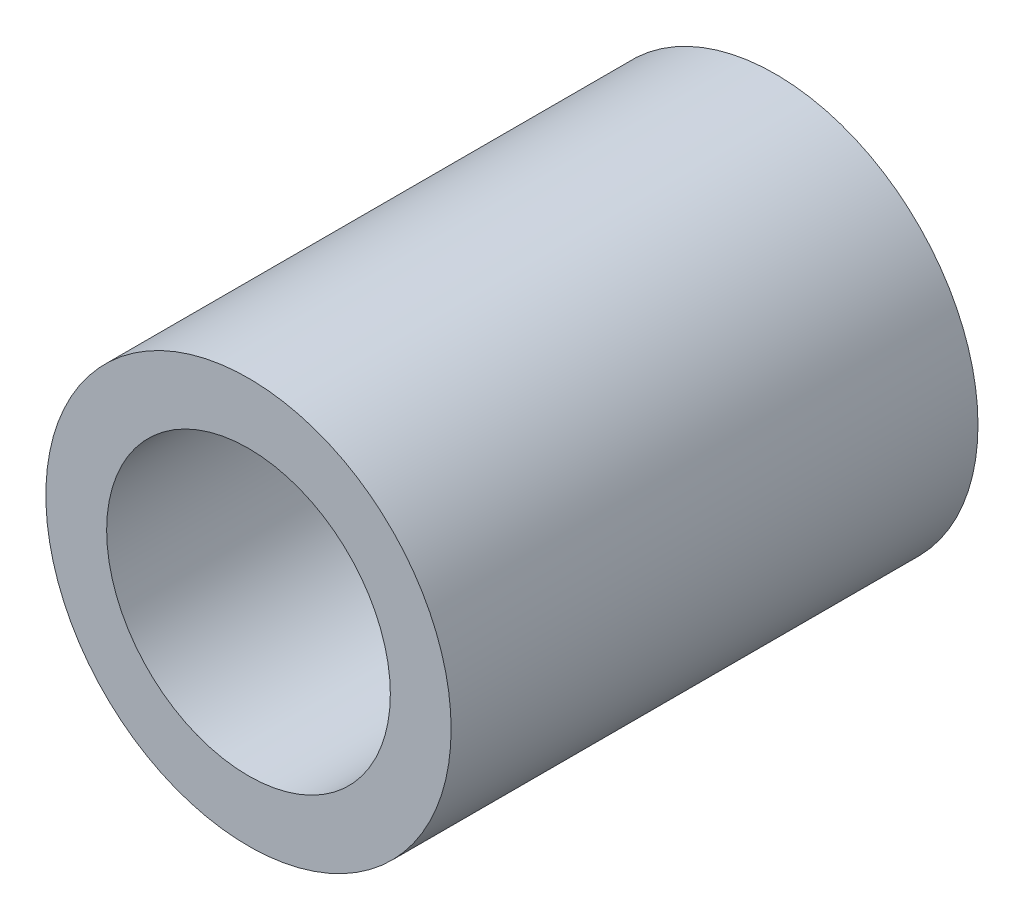
from build123d import *

# Parameters (mm, degrees)
ESBO_O1_R                = 2.5
ESBO_O1_R_2              = 1.75
RESSALTO_EXTRUS_O1_DEPTH = 6.5


with BuildPart() as part:
    # Esboço1 → Ressalto-extrusão1 (new body)
    with BuildSketch(Plane.XY):
        Circle(ESBO_O1_R)
        Circle(ESBO_O1_R_2, mode=Mode.SUBTRACT)
    extrude(amount=RESSALTO_EXTRUS_O1_DEPTH)


solid = part.part
